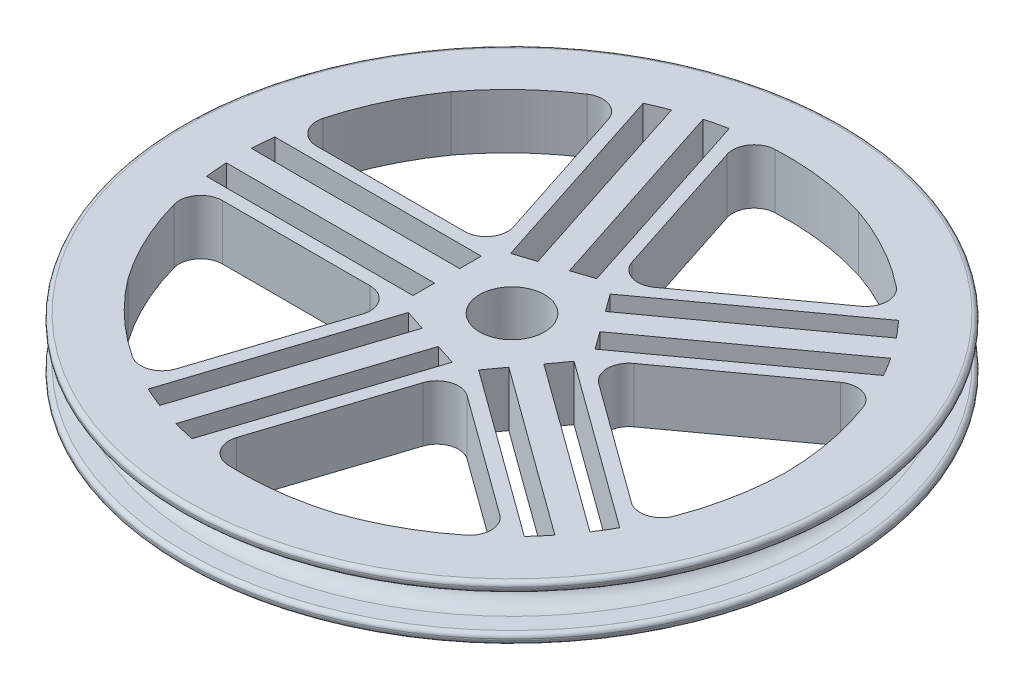
from build123d import *

# Parameters (mm, degrees)
SKETCH2_R           = 7.5
CUT_EXTRUDE3_DEPTH  = 13.7
CUT_EXTRUDE7_START  = -13.7
CUT_EXTRUDE7_DEPTH  = 14.7
CIRPATTERN1_COUNT   = 5
FILLET1_R           = 5
FILLET2_R           = 5
BOSS_EXTRUDE1_DEPTH = 10


with BuildPart() as part:
    # Sketch1 → Revolve2 (revolve)
    with BuildSketch(Plane.XY):
        with BuildLine():
            Line((0, 8), (-4, 8))
            ThreePointArc((-4, 8), (-4.707107, 8.292893), (-5, 9))
            Line((-5, 9), (-5, 9.35))
            ThreePointArc((-5, 9.35), (-4.707107, 10.057107), (-4, 10.35))
            Line((-4, 10.35), (71.2, 10.35))
            Line((71.2, 10.35), (71.2, -2.35))
            Line((71.2, -2.35), (-4, -2.35))
            ThreePointArc((-4, -2.35), (-4.707107, -2.057107), (-5, -1.35))
            Line((-5, -1.35), (-5, -1))
            ThreePointArc((-5, -1), (-4.707107, -0.292893), (-4, 0))
            Line((-4, 0), (0, 0))
            ThreePointArc((0, 0), (4, 4), (0, 8))
        make_face()
    revolve(axis=Axis((71.2, 10.35, 0), (0, -1, 0)))

    # Sketch2 → Cut-Extrude3 (cut, through all)
    with BuildSketch(Plane.XZ.offset(2.35)):
        with Locations((71.2, 0)):
            Circle(SKETCH2_R)
    extrude(amount=-CUT_EXTRUDE3_DEPTH, mode=Mode.SUBTRACT)

    # Sketch3 → Cut-Extrude7 (cut)
    with BuildSketch(Plane.XZ.offset(2.35).offset(CUT_EXTRUDE7_START)):
        with BuildLine():
            Line((90.835255, 60.431101), (76.92949, 17.633558))
            Line((76.92949, 17.633558), (115.185507, 45.428181))
            ThreePointArc((115.185507, 45.428181), (103.845808, 54.285567), (90.835255, 60.431101))
        make_face()
        with BuildLine():
            Line((78.692846, 15.206507), (81.631772, 11.161422))
            Line((81.631772, 11.161422), (120.579888, 39.458884))
            ThreePointArc((120.579888, 39.458884), (118.978427, 41.390499), (117.303607, 43.258867))
            Line((117.303607, 43.258867), (78.692846, 15.206507))
        make_face()
        with BuildLine():
            Line((85.038738, 6.472136), (87.977664, 2.427051))
            Line((87.977664, 2.427051), (126.588425, 30.479411))
            ThreePointArc((126.588425, 30.479411), (125.32905, 32.649616), (123.986854, 34.769599))
            Line((123.986854, 34.769599), (85.038738, 6.472136))
        make_face()
        with BuildLine():
            Line((127.997037, 27.794623), (89.74102, 0))
            Line((89.74102, 0), (134.74102, 0))
            ThreePointArc((134.74102, 0), (132.916752, 14.272845), (127.997037, 27.794623))
        make_face()
    cut_extrude7 = extrude(amount=CUT_EXTRUDE7_DEPTH, mode=Mode.SUBTRACT)

    # CirPattern1: Cut-Extrude7 ×5 about axis
    cirpattern1_axis = Axis((71.2, 0, 0), (0, 1, 0))
    for i in range(1, CIRPATTERN1_COUNT):
        add(cut_extrude7.rotate(cirpattern1_axis, i * 360 / CIRPATTERN1_COUNT), mode=Mode.SUBTRACT)

    # Fillet1
    fillet1_edges = [part.edges().sort_by_distance(p)[0] for p in [
        (76.92949, 4, -17.633558),
        (56.2, 4, -10.898138),
        (56.2, 4, 10.898138),
        (89.74102, 4, 0),
        (76.92949, 4, 17.633558),
    ]]
    fillet(fillet1_edges, radius=FILLET1_R)

    # Fillet2
    fillet2_edges = [part.edges().sort_by_distance(p)[0] for p in [
        (62.316992, 4, -62.606203),
        (115.185507, 4, -45.428181),
        (62.316992, 4, 62.606203),
        (8.912963, 4, -10.898138),
        (41.587502, 4, -55.870783),
        (127.997037, 4, -27.794623),
        (41.587502, 4, 55.870783),
        (8.912963, 4, 10.898138),
        (127.997037, 4, 27.794623),
        (115.185507, 4, 45.428181),
    ]]
    fillet(fillet2_edges, radius=FILLET2_R)

    # Sketch5 → Boss-Extrude1 (add)
    with BuildSketch(Plane.XZ.offset(2.35)):
        with BuildLine():
            ThreePointArc((68.81, 7.109001), (69.989114, 7.401605), (71.2, 7.5))
            Line((71.2, 7.5), (71.2, 9.89))
            Line((71.2, 9.89), (68.81, 9.89))
            Line((68.81, 9.89), (68.81, 7.109001))
        make_face()
        with BuildLine():
            Line((71.2, 9.89), (71.2, 7.5))
            ThreePointArc((71.2, 7.5), (72.410886, 7.401605), (73.59, 7.109001))
            Line((73.59, 7.109001), (73.59, 9.89))
            Line((73.59, 9.89), (71.2, 9.89))
        make_face()
        with BuildLine():
            ThreePointArc((73.59, 7.109001), (72.410886, 7.401605), (71.2, 7.5))
            Line((71.2, 7.5), (71.2, 5.1275))
            Line((71.2, 5.1275), (73.59, 5.1275))
            Line((73.59, 5.1275), (73.59, 7.109001))
        make_face()
        with BuildLine():
            Line((71.2, 5.1275), (71.2, 7.5))
            ThreePointArc((71.2, 7.5), (69.989114, 7.401605), (68.81, 7.109001))
            Line((68.81, 7.109001), (68.81, 5.1275))
            Line((68.81, 5.1275), (71.2, 5.1275))
        make_face()
    extrude(amount=-BOSS_EXTRUDE1_DEPTH)


solid = part.part
